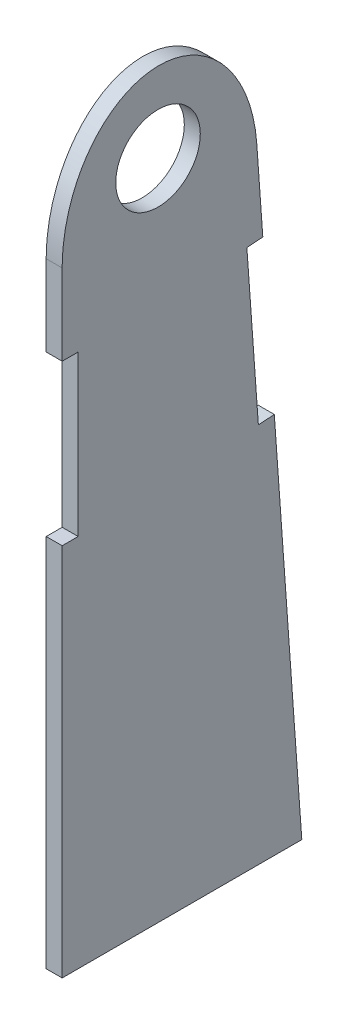
from build123d import *

# Parameters (mm, degrees)
BOSS_EXTRUDE1_DEPTH  = 1.5875
M8_CLEARANCE_HOLE1_D = 8.4
CUT_EXTRUDE1_DEPTH   = 2.5875


with BuildPart() as part:
    # Sketch1 → Boss-Extrude1 (new body)
    with BuildSketch(Plane(origin=(0, 0, 0), x_dir=(0, 0, -1), z_dir=(1, 0, 0))):
        with BuildLine():
            Line((-9.525, -65.774638339), (0, -65.774638339))
            Line((0, -65.774638339), (14.2875, -65.774638339))
            Line((14.2875, -65.774638339), (11.553356238, -27.816833207))
            Line((11.553356238, -27.816833207), (9.96995864, -27.930887132))
            Line((9.96995864, -27.930887132), (8.829419389, -12.096911155))
            Line((8.829419389, -12.096911155), (10.412816987, -11.98285723))
            Line((10.412816987, -11.98285723), (9.500385586, 0.684323551))
            ThreePointArc((9.500385586, 0.684323551), (-0.342383043, 9.518844407), (-9.525, 0))
            Line((-9.525, 0), (-9.525, -12.7))
            Line((-9.525, -12.7), (-7.9375, -12.7))
            Line((-7.9375, -12.7), (-7.9375, -28.575))
            Line((-7.9375, -28.575), (-9.525, -28.575))
            Line((-9.525, -28.575), (-9.525, -65.774638339))
        make_face()
    extrude(amount=BOSS_EXTRUDE1_DEPTH)

    # M8 Clearance Hole1 (through all)
    with Locations(Plane(origin=(1.5875, 0, 0), x_dir=(0, 0, -1), z_dir=(1, 0, 0))):
        with Locations((0, 0)):
            Hole(M8_CLEARANCE_HOLE1_D / 2)

    # Sketch4 → Cut-Extrude1 (cut, through all)
    with BuildSketch(Plane(origin=(1.5875, 0, 0), x_dir=(0, 0, -1), z_dir=(1, 0, 0))):
        with BuildLine():
            Line((9.813193489, -3.658352794), (9.500385586, 0.684323551))
            ThreePointArc((9.500385586, 0.684323551), (-0.342383043, 9.518844407), (-9.525, 0))
            Line((-9.525, 0), (-9.525, -4.671809667))
            add(Edge.make_bspline(
                [(9.813193489, -3.658352794), (8.943756668, 8.411939147), (-0.290621666, 7.927993001), (-9.525, 7.444046856), (-9.525, -4.671809667)],
                knots=[1.647896538, 1.647896538, 1.647896538, 3.171599371, 3.171599371, 4.695302204, 4.695302204, 4.695302204], degree=2, weights=[1, 0.723559289, 1, 0.723559289, 1]))
        make_face()
    extrude(amount=-CUT_EXTRUDE1_DEPTH, mode=Mode.SUBTRACT)


solid = part.part
